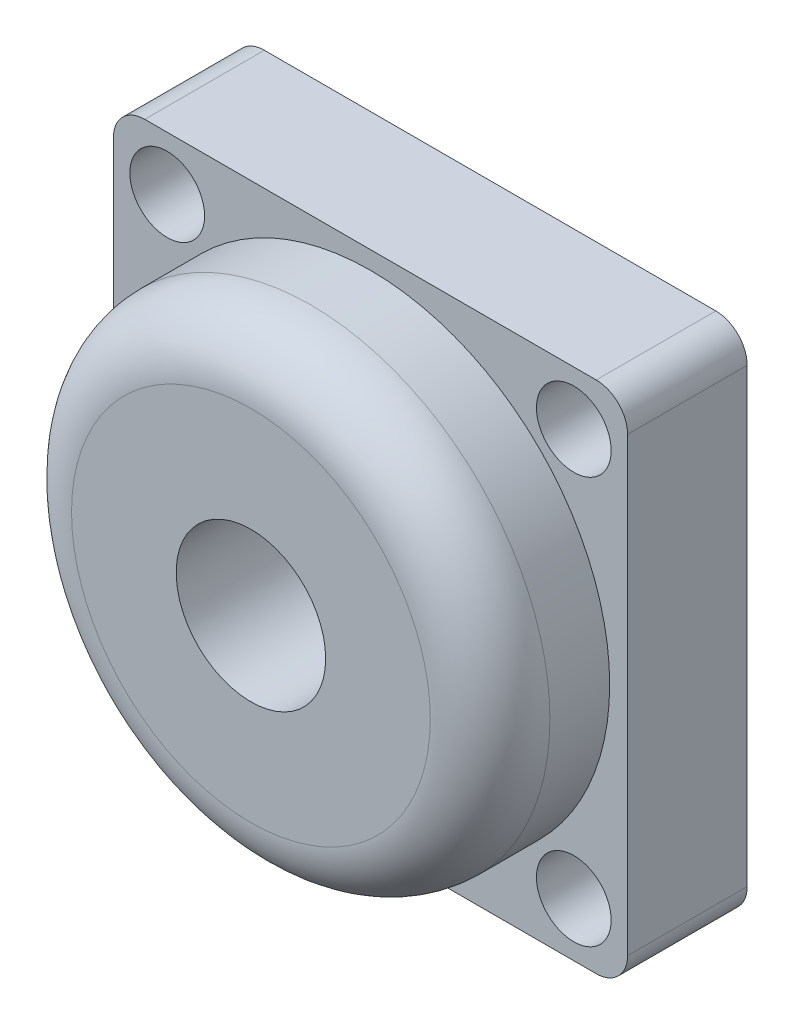
from build123d import *

# Parameters (mm, degrees)
BOSS_EXTRUDE1_DEPTH = 20
SKETCH2_R           = 40
BOSS_EXTRUDE2_DEPTH = 20
SKETCH3_R           = 12.5
SKETCH3_R_2         = 6.25
CUT_EXTRUDE1_DEPTH  = 41
FILLET1_R           = 10


with BuildPart() as part:
    # Sketch1 → Boss-Extrude1 (new body)
    with BuildSketch(Plane.XY):
        with BuildLine():
            Line((37.75, -43), (-37.75, -43))
            ThreePointArc((-37.75, -43), (-41.462310601, -41.462310601), (-43, -37.75))
            Line((-43, -37.75), (-43, 37.75))
            ThreePointArc((-43, 37.75), (-41.462310601, 41.462310601), (-37.75, 43))
            Line((-37.75, 43), (37.75, 43))
            ThreePointArc((37.75, 43), (41.462310601, 41.462310601), (43, 37.75))
            Line((43, 37.75), (43, -37.75))
            ThreePointArc((43, -37.75), (41.462310601, -41.462310601), (37.75, -43))
        make_face()
    extrude(amount=BOSS_EXTRUDE1_DEPTH)

    # Sketch2 → Boss-Extrude2 (add)
    with BuildSketch(Plane.XY.offset(20)):
        Circle(SKETCH2_R)
    extrude(amount=BOSS_EXTRUDE2_DEPTH)

    # Sketch3 → Cut-Extrude1 (cut, through all)
    with BuildSketch(Plane.XY.offset(40)):
        Circle(SKETCH3_R)
        with Locations((-34, 34)):
            Circle(SKETCH3_R_2)
        with Locations((34, 34)):
            Circle(SKETCH3_R_2)
        with Locations((34, -34)):
            Circle(SKETCH3_R_2)
        with Locations((-34, -34)):
            Circle(SKETCH3_R_2)
    extrude(amount=-CUT_EXTRUDE1_DEPTH, mode=Mode.SUBTRACT)

    # Fillet1
    fillet1_edges = [part.edges().sort_by_distance(p)[0] for p in [
        (-40, 0, 40),
    ]]
    fillet(fillet1_edges, radius=FILLET1_R)


solid = part.part
